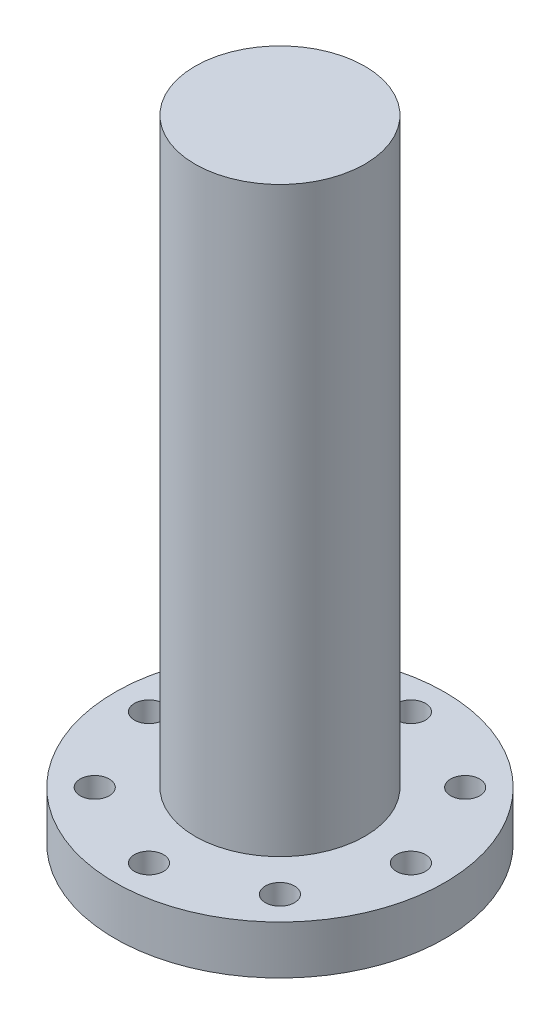
from build123d import *

# Parameters (mm, degrees)
SKETCH3_R          = 3
CUT_EXTRUDE1_DEPTH = 131


with BuildPart() as part:
    # Sketch2 → Revolve1 (revolve)
    with BuildSketch(Plane(origin=(0, 0, 0), x_dir=(0, 0, -1), z_dir=(1, 0, 0))):
        Polygon((0, 0), (34, 0), (34, 10), (17.5, 10), (17.5, 130), (0, 130), align=None)
    revolve(axis=Axis((0, 0, 0), (0, 1, 0)))

    # Sketch3 → Cut-Extrude1 (cut, through all)
    with BuildSketch(Plane.XZ):
        with Locations((27, 0)):
            Circle(SKETCH3_R)
        with Locations((19.091883092, -19.091883092)):
            Circle(SKETCH3_R)
        with Locations((0, -27)):
            Circle(SKETCH3_R)
        with Locations((-19.091883092, -19.091883092)):
            Circle(SKETCH3_R)
        with Locations((-27, 0)):
            Circle(SKETCH3_R)
        with Locations((-19.091883092, 19.091883092)):
            Circle(SKETCH3_R)
        with Locations((0, 27)):
            Circle(SKETCH3_R)
        with Locations((19.091883092, 19.091883092)):
            Circle(SKETCH3_R)
    extrude(amount=-CUT_EXTRUDE1_DEPTH, mode=Mode.SUBTRACT)


solid = part.part
